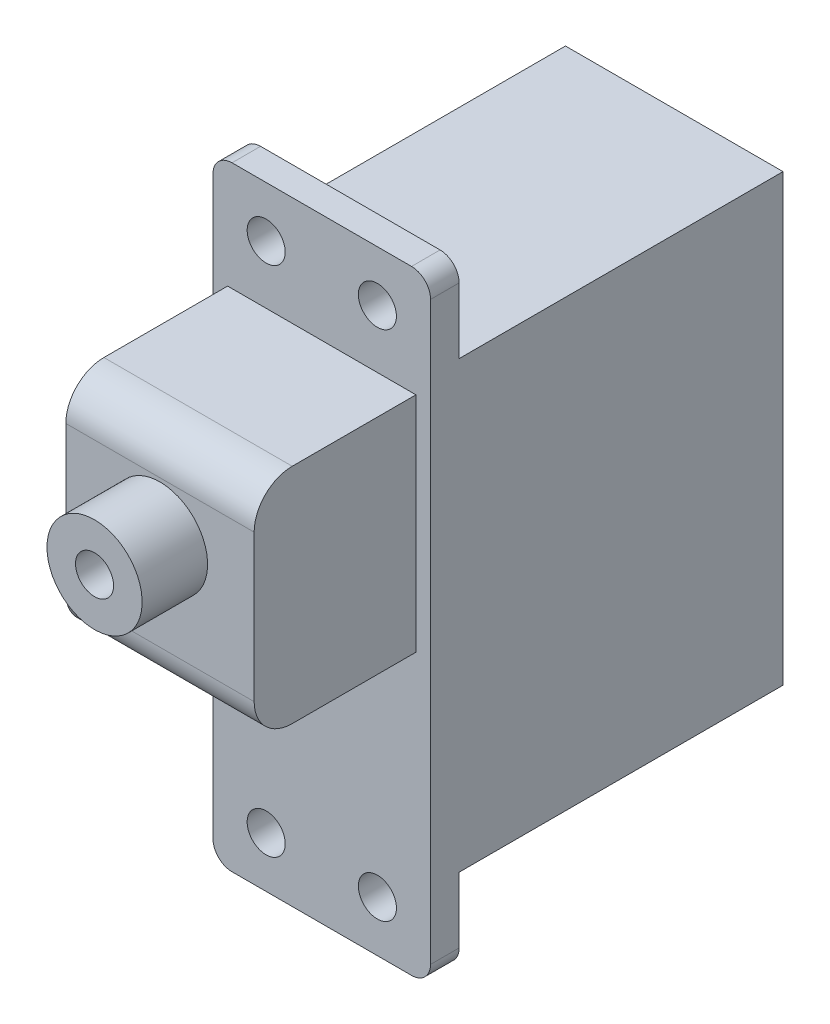
from build123d import *

# Parameters (mm, degrees)
ESQUISSE1_W                       = 18.518
ESQUISSE1_H                       = 32.258
BOSS_EXTRU_1_DEPTH                = 11.43
ESQUISSE2_W                       = 17.018
ESQUISSE2_H                       = 4.444999993
ENL_V_MAT_EXTRU_1_DEPTH           = 12.43
ESQUISSE3_W                       = 17.018000001
ESQUISSE3_H                       = 4.444999993
ENL_V_MAT_EXTRU_2_DEPTH           = 12.43
ESQUISSE4_W                       = 9.89372273
ESQUISSE4_H                       = 11.711081898
BOSS_EXTRU_2_DEPTH                = 8.5
ESQUISSE5_W                       = 2.5
ESQUISSE5_H                       = 3.438
DIAM_TRE_DU_PER_AGE_2_0_2_1_D     = 2
DIAM_TRE_DU_PER_AGE_2_0_2_1_DEPTH = 2
DIAM_TRE_DU_PER_AGE_2_0_2_2_D     = 2
DIAM_TRE_DU_PER_AGE_2_0_2_2_DEPTH = 13.438
CONG_1_R                          = 1
CONG_2_R                          = 2


with BuildPart() as part:
    # Esquisse1 → Boss.-Extru.1 (new body)
    with BuildSketch(Plane(origin=(11.43, 0, 0), x_dir=(0, 0, -1), z_dir=(1, 0, 0))):
        with Locations((7.759, 11.684)):
            Rectangle(ESQUISSE1_W, ESQUISSE1_H)
    extrude(amount=-BOSS_EXTRU_1_DEPTH)

    # Esquisse2 → Enlèv. mat.-Extru.1 (cut, through all)
    with BuildSketch(Plane.ZY):
        with Locations((-8.509, -2.222500003)):
            Rectangle(ESQUISSE2_W, ESQUISSE2_H)
    extrude(amount=-ENL_V_MAT_EXTRU_1_DEPTH, mode=Mode.SUBTRACT)

    # Esquisse3 → Enlèv. mat.-Extru.2 (cut, through all)
    with BuildSketch(Plane.ZY):
        with Locations((-8.509, 25.590500004)):
            Rectangle(ESQUISSE3_W, ESQUISSE3_H)
    extrude(amount=-ENL_V_MAT_EXTRU_2_DEPTH, mode=Mode.SUBTRACT)

    # Esquisse4 → Boss.-Extru.2 (add)
    with BuildSketch(Plane.XY.offset(1.5)):
        with Locations((5.715, 16.232232421)):
            Rectangle(ESQUISSE4_W, ESQUISSE4_H)
    extrude(amount=BOSS_EXTRU_2_DEPTH)

    # Esquisse5 → Révolution1 (revolve)
    with BuildSketch(Plane.XZ.offset(-17.399)):
        with Locations((6.965, 11.719)):
            Rectangle(ESQUISSE5_W, ESQUISSE5_H)
    revolve(axis=Axis((5.715, 17.399, 13.438), (0, 0, -1)))

    # Diamètre du perçage Ø2.0 (2)1
    with Locations(Plane.XY.offset(13.438)):
        with Locations((5.715, 17.399)):
            Hole(DIAM_TRE_DU_PER_AGE_2_0_2_1_D / 2, depth=DIAM_TRE_DU_PER_AGE_2_0_2_1_DEPTH)

    # Diamètre du perçage Ø2.0 (2)2
    with Locations(Plane(origin=(0, 0, 0), x_dir=(-1, 0, 0), z_dir=(0, 0, -1))):
        with Locations((-2.794, -1.778), (-8.636, -1.778), (-8.636, 25.146), (-2.794, 25.146)):
            Hole(DIAM_TRE_DU_PER_AGE_2_0_2_2_D / 2, depth=DIAM_TRE_DU_PER_AGE_2_0_2_2_DEPTH)

    # Congé1
    cong_1_edges = [part.edges().sort_by_distance(p)[0] for p in [
        (11.43, 27.813, 0.75),
        (0, 27.813, 0.75),
        (11.43, -4.445, 0.75),
        (0, -4.445, 0.75),
    ]]
    fillet(cong_1_edges, radius=CONG_1_R)

    # Congé2
    cong_2_edges = [part.edges().sort_by_distance(p)[0] for p in [
        (5.715, 10.376691472, 10),
        (5.715, 22.08777337, 10),
    ]]
    fillet(cong_2_edges, radius=CONG_2_R)


solid = part.part
